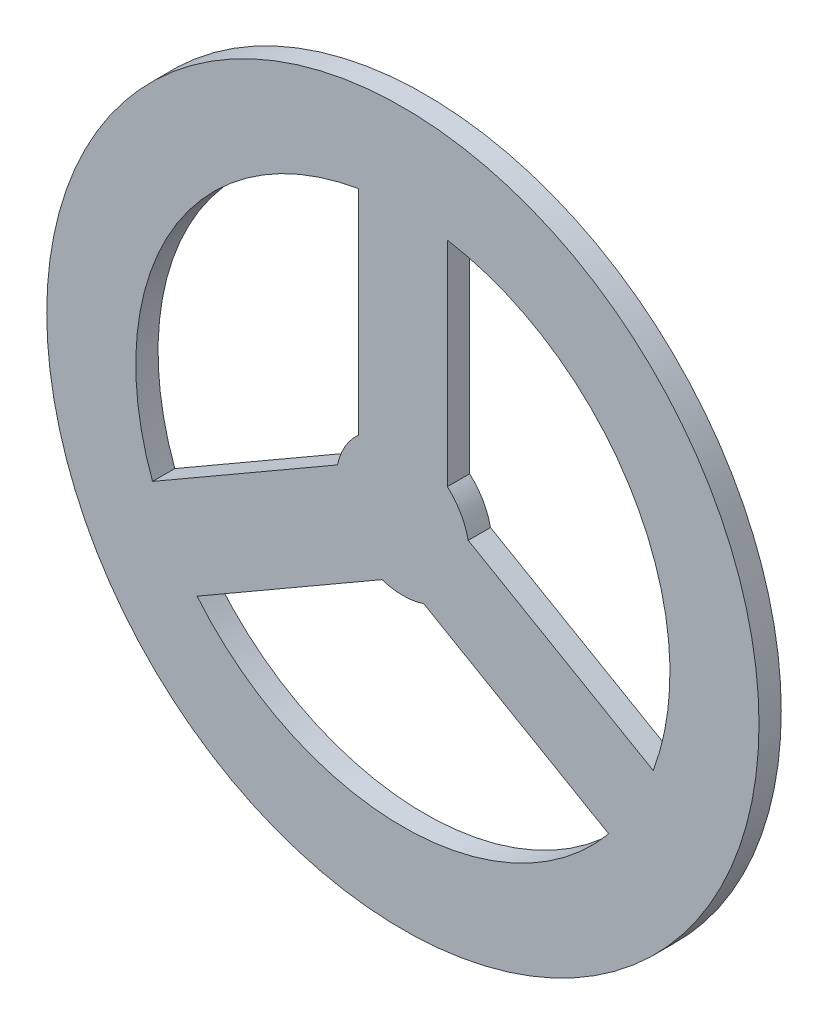
from build123d import *

# Parameters (mm, degrees)
SKETCH1_R           = 101.6
BOSS_EXTRUDE1_DEPTH = 6.35
SCALE1_SCALE        = 0.4


with BuildPart() as part:
    # Sketch1 → Boss-Extrude1 (new body)
    with BuildSketch(Plane.XY):
        Circle(SKETCH1_R)
        with BuildLine():
            Line((-12.7, 14.199031657), (-12.7, 75.134213245))
            ThreePointArc((-12.7, 75.134213245), (-65.991135768, 38.1), (-71.418137364, -26.568583995))
            Line((-71.418137364, -26.568583995), (-18.646722124, 3.8990068))
            ThreePointArc((-18.646722124, 3.8990068), (-16.497783942, 9.525), (-12.7, 14.199031657))
        make_face(mode=Mode.SUBTRACT)
        with BuildLine():
            Line((12.7, 14.199031657), (12.7, 75.134213245))
            ThreePointArc((12.7, 75.134213245), (65.991135768, 38.1), (71.418137364, -26.568583995))
            Line((71.418137364, -26.568583995), (18.646722124, 3.8990068))
            ThreePointArc((18.646722124, 3.8990068), (16.497783942, 9.525), (12.7, 14.199031657))
        make_face(mode=Mode.SUBTRACT)
        with BuildLine():
            Line((5.946722124, -18.098038457), (58.718137364, -48.565629251))
            ThreePointArc((58.718137364, -48.565629251), (0, -76.2), (-58.718137364, -48.565629251))
            Line((-58.718137364, -48.565629251), (-5.946722124, -18.098038457))
            ThreePointArc((-5.946722124, -18.098038457), (0, -19.05), (5.946722124, -18.098038457))
        make_face(mode=Mode.SUBTRACT)
    extrude(amount=BOSS_EXTRUDE1_DEPTH)


with BuildPart() as part_1:
    # Scale1: scaled about (0, 0, 3.175)
    add(part.part.scale(SCALE1_SCALE).moved(Location((0, 0, 1.905))))


solid = part_1.part
